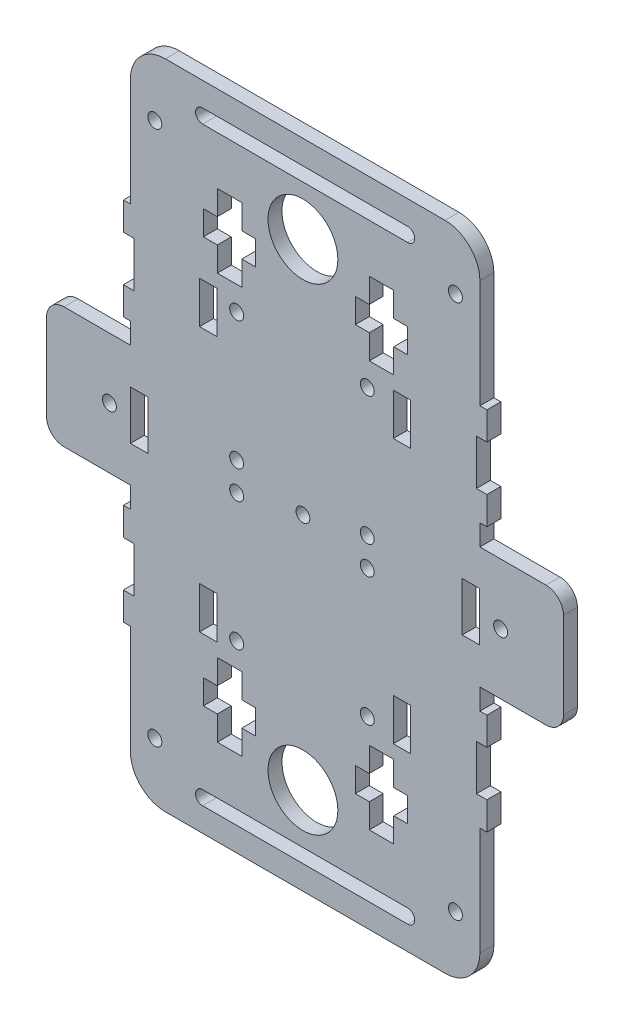
from build123d import *

# Parameters (mm, degrees)
SKETCH1_R           = 10
SKETCH1_R_2         = 1.972602619
BOSS_EXTRUDE2_DEPTH = 4
SKETCH5_W           = 5
SKETCH5_H           = 14
CUT_EXTRUDE3_DEPTH  = 5.0000001
SKETCH6_W           = 5
SKETCH6_H           = 14
CUT_EXTRUDE4_DEPTH  = 5.0000001
SKETCH19_R          = 2
CUT_EXTRUDE19_DEPTH = 5.0000001
SKETCH22_R          = 2
CUT_EXTRUDE22_DEPTH = 5.0000001
SKETCH23_R          = 2
CUT_EXTRUDE23_DEPTH = 5.0000001
SKETCH24_R          = 2
CUT_EXTRUDE24_DEPTH = 5.0000001
SKETCH25_W          = 5
SKETCH25_H          = 12
CUT_EXTRUDE25_DEPTH = 5.0000001
CUT_EXTRUDE26_DEPTH = 5.0000001
CUT_EXTRUDE29_DEPTH = 5.0000001
SKETCH20_R          = 2
CUT_EXTRUDE20_DEPTH = 5.0000001
SKETCH30_W          = 181.696441894
SKETCH30_H          = 131.456906608
CUT_EXTRUDE30_DEPTH = 4
SKETCH31_R          = 2
CUT_EXTRUDE31_DEPTH = 4
SKETCH32_W          = 167.461823271
SKETCH32_H          = 37.26795508
CUT_EXTRUDE32_DEPTH = 4
FILLET1_R           = 10
FILLET2_R           = 5
SKETCH33_W          = 2
SKETCH33_H          = 8
BOSS_EXTRUDE3_DEPTH = 4


with BuildPart() as part:
    # Sketch1 → Boss-Extrude2 (new body)
    with BuildSketch(Plane.XY):
        with BuildLine():
            Line((-49.4, 97.775402254), (-49.4, 48.775402254))
            Line((-49.4, 48.775402254), (-48.4, 48.775402254))
            Line((-48.4, 48.775402254), (-48.4, 35.775402254))
            Line((-48.4, 35.775402254), (-49.4, 35.775402254))
            Line((-49.4, 35.775402254), (-49.4, 21.775402254))
            Line((-49.4, 21.775402254), (-73.4, 21.775402254))
            Line((-73.4, 21.775402254), (-73.4, -12.924597746))
            Line((-73.4, -12.924597746), (-49.4, -12.924597746))
            Line((-49.4, -12.924597746), (-49.4, -26.924597746))
            Line((-49.4, -26.924597746), (-48.4, -26.924597746))
            Line((-48.4, -26.924597746), (-48.4, -39.924597746))
            Line((-48.4, -39.924597746), (-49.4, -39.924597746))
            Line((-49.4, -39.924597746), (-49.4, -88.924597746))
            Line((-49.4, -88.924597746), (-73.349457369, -88.924597746))
            add(Edge.make_bspline(
                [(-73.349457369, -88.924597746), (-70.502213021, -123.490651401), (3.447241601, -123.490651401), (77.396696223, -123.490651401), (74.549451875, -88.924597746)],
                knots=[3.190793702, 3.190793702, 3.190793702, 4.761590029, 4.761590029, 6.332386355, 6.332386355, 6.332386355], degree=2, weights=[1, 0.707106781, 1, 0.707106781, 1]))
            Line((74.549451875, -88.924597746), (50.599994505, -88.924597746))
            Line((50.599994505, -88.924597746), (50.599994505, -39.924597746))
            Line((50.599994505, -39.924597746), (49.599994505, -39.924597746))
            Line((49.599994505, -39.924597746), (49.599994505, -26.924597746))
            Line((49.599994505, -26.924597746), (50.599994505, -26.924597746))
            Line((50.599994505, -26.924597746), (50.599994505, -12.924597746))
            Line((50.599994505, -12.924597746), (74.599994505, -12.924597746))
            Line((74.599994505, -12.924597746), (74.599994505, 21.775402254))
            Line((74.599994505, 21.775402254), (50.669116659, 21.775402254))
            Line((50.669116659, 21.775402254), (50.669116659, 35.775402254))
            Line((50.669116659, 35.775402254), (49.669116659, 35.775402254))
            Line((49.669116659, 35.775402254), (49.669116659, 48.775402254))
            Line((49.669116659, 48.775402254), (50.669116659, 48.775402254))
            Line((50.669116659, 48.775402254), (50.669116659, 97.775402254))
            Line((50.669116659, 97.775402254), (74.669116659, 97.775402254))
            add(Edge.make_bspline(
                [(74.669116659, 97.775402254), (74.669116659, 132.775402254), (0.587265356, 132.775402254), (-73.494585946, 132.775402254), (-73.494585946, 97.775402254)],
                knots=[3.141592654, 3.141592654, 3.141592654, 4.71238898, 4.71238898, 6.283185307, 6.283185307, 6.283185307], degree=2, weights=[1, 0.707106781, 1, 0.707106781, 1]))
            Line((-73.494585946, 97.775402254), (-49.4, 97.775402254))
        make_face()
        with Locations((0, 72.732378713)):
            Circle(SKETCH1_R, mode=Mode.SUBTRACT)
        with Locations((0, -63.883577786)):
            Circle(SKETCH1_R, mode=Mode.SUBTRACT)
        with Locations((0, 4.424400463)):
            Circle(SKETCH1_R_2, mode=Mode.SUBTRACT)
    extrude(amount=BOSS_EXTRUDE2_DEPTH)

    # Sketch5 → Cut-Extrude3 (cut, through all)
    with BuildSketch(Plane(origin=(0, 0, 0), x_dir=(-1, 0, 0), z_dir=(0, 0, -1))):
        with Locations((46.9, 4.425402254)):
            Rectangle(SKETCH5_W, SKETCH5_H)
    extrude(amount=-CUT_EXTRUDE3_DEPTH, mode=Mode.SUBTRACT)

    # Sketch6 → Cut-Extrude4 (cut, through all)
    with BuildSketch(Plane(origin=(0, 0, 0), x_dir=(-1, 0, 0), z_dir=(0, 0, -1))):
        with Locations((-48.099994505, 4.425402254)):
            Rectangle(SKETCH6_W, SKETCH6_H)
    extrude(amount=-CUT_EXTRUDE4_DEPTH, mode=Mode.SUBTRACT)

    # Sketch19 → Cut-Extrude19 (cut, through all)
    with BuildSketch(Plane(origin=(0, 0, 0), x_dir=(-1, 0, 0), z_dir=(0, 0, -1))):
        with Locations((-56.599994505, 4.425402254)):
            Circle(SKETCH19_R)
    extrude(amount=-CUT_EXTRUDE19_DEPTH, mode=Mode.SUBTRACT)

    # Sketch22 → Cut-Extrude22 (cut, through all)
    with BuildSketch(Plane(origin=(0, 0, 0), x_dir=(-1, 0, 0), z_dir=(0, 0, -1))):
        with Locations((42.4, 81)):
            Circle(SKETCH22_R)
        with Locations((-43.669116659, 81)):
            Circle(SKETCH22_R)
    extrude(amount=-CUT_EXTRUDE22_DEPTH, mode=Mode.SUBTRACT)

    # Sketch23 → Cut-Extrude23 (cut, through all)
    with BuildSketch(Plane.XY.offset(4)):
        with Locations((43.599994505, -81)):
            Circle(SKETCH23_R)
        with Locations((-42.4, -81)):
            Circle(SKETCH23_R)
    extrude(amount=-CUT_EXTRUDE23_DEPTH, mode=Mode.SUBTRACT)

    # Sketch24 → Cut-Extrude24 (cut, through all)
    with BuildSketch(Plane.XY.offset(4)):
        with Locations((-50, -94.924597746)):
            Circle(SKETCH24_R)
        with Locations((50, -94.924597746)):
            Circle(SKETCH24_R)
        with Locations((-50, 103.775402254)):
            Circle(SKETCH24_R)
        with Locations((50, 103.775402254)):
            Circle(SKETCH24_R)
    extrude(amount=-CUT_EXTRUDE24_DEPTH, mode=Mode.SUBTRACT)

    # Sketch25 → Cut-Extrude25 (cut, through all)
    with BuildSketch(Plane(origin=(0, 0, 0), x_dir=(-1, 0, 0), z_dir=(0, 0, -1))):
        with Locations((-28.369116659, 42.275402254)):
            Rectangle(SKETCH25_W, SKETCH25_H)
        with Locations((27.1, 42.275402254)):
            Rectangle(SKETCH25_W, SKETCH25_H)
        with Locations((-28.299994505, -33.424597746)):
            Rectangle(SKETCH25_W, SKETCH25_H)
        with Locations((27.1, -33.424597746)):
            Rectangle(SKETCH25_W, SKETCH25_H)
    extrude(amount=-CUT_EXTRUDE25_DEPTH, mode=Mode.SUBTRACT)

    # Sketch26 → Cut-Extrude26 (cut, through all)
    with BuildSketch(Plane(origin=(0, 0, 0), x_dir=(-1, 0, 0), z_dir=(0, 0, -1))):
        Polygon((24.510151311, 52.075402254), (17.510151311, 52.075402254), (17.510151311, 59.075402254), (13.510151311, 59.075402254), (13.510151311, 66.075402254), (17.510151311, 66.075402254), (17.510151311, 73.075402254), (24.510151311, 73.075402254), (24.510151311, 66.075402254), (28.510151311, 66.075402254), (28.510151311, 59.075402254), (24.510151311, 59.075402254), align=None)
        Polygon((-29.999116659, 59.075402254), (-29.999116659, 66.075402254), (-25.999116659, 66.075402254), (-25.999116659, 73.075402254), (-18.999116659, 73.075402254), (-18.999116659, 66.075402254), (-14.999116659, 66.075402254), (-14.999116659, 59.075402254), (-18.999116659, 59.075402254), (-18.999116659, 52.075402254), (-25.999116659, 52.075402254), (-25.999116659, 59.075402254), align=None)
        Polygon((-19, -69), (-19, -62), (-15, -62), (-15, -55), (-19, -55), (-19, -48), (-26, -48), (-26, -55), (-30, -55), (-30, -62), (-26, -62), (-26, -69), align=None)
        Polygon((24.510151311, -48), (17.510151311, -48), (17.510151311, -55), (13.510151311, -55), (13.510151311, -62), (17.510151311, -62), (17.510151311, -69), (24.510151311, -69), (24.510151311, -62), (28.510151311, -62), (28.510151311, -55), (24.510151311, -55), align=None)
    extrude(amount=-CUT_EXTRUDE26_DEPTH, mode=Mode.SUBTRACT)

    # Sketch28 → Cut-Extrude29 (cut, through all)
    with BuildSketch(Plane(origin=(0, 0, 0), x_dir=(-1, 0, 0), z_dir=(0, 0, -1))):
        with BuildLine():
            Line((28.730883341, 86.928533544), (-30, 86.928533544))
            ThreePointArc((-30, 86.928533544), (-32, 88.928533544), (-30, 90.928533544))
            Line((-30, 90.928533544), (28.730883341, 90.928533544))
            ThreePointArc((28.730883341, 90.928533544), (30.730883341, 88.928533544), (28.730883341, 86.928533544))
        make_face()
    extrude(amount=-CUT_EXTRUDE29_DEPTH, mode=Mode.SUBTRACT)

    # Sketch20 → Cut-Extrude20 (cut, through all)
    with BuildSketch(Plane(origin=(0, 0, 0), x_dir=(-1, 0, 0), z_dir=(0, 0, -1))):
        with Locations((55.4, 4.425402254)):
            Circle(SKETCH20_R)
    extrude(amount=-CUT_EXTRUDE20_DEPTH, mode=Mode.SUBTRACT)

    # Sketch30 → Cut-Extrude30 (cut)
    with BuildSketch(Plane(origin=(0, 0, 0), x_dir=(-1, 0, 0), z_dir=(0, 0, -1))):
        with Locations((-2.534318945, -61.30305105)):
            Rectangle(SKETCH30_W, SKETCH30_H)
    extrude(amount=-CUT_EXTRUDE30_DEPTH, mode=Mode.SUBTRACT)

    # Sketch31 → Cut-Extrude31 (cut)
    with BuildSketch(Plane(origin=(0, 0, 0), x_dir=(-1, 0, 0), z_dir=(0, 0, -1))):
        with Locations((-18.412976441, 45.21289193)):
            Circle(SKETCH31_R)
        with Locations((-18.413659383, 8.47289193)):
            Circle(SKETCH31_R)
        with Locations((18.967023559, 45.21289193)):
            Circle(SKETCH31_R)
        with Locations((18.966340617, 8.47289193)):
            Circle(SKETCH31_R)
    extrude(amount=-CUT_EXTRUDE31_DEPTH, mode=Mode.SUBTRACT)

    # Sketch32 → Cut-Extrude32 (cut)
    with BuildSketch(Plane(origin=(0, 0, 0), x_dir=(-1, 0, 0), z_dir=(0, 0, -1))):
        with Locations((-4.661465148, 116.409379794)):
            Rectangle(SKETCH32_W, SKETCH32_H)
    extrude(amount=-CUT_EXTRUDE32_DEPTH, mode=Mode.SUBTRACT)

    # Fillet1
    fillet1_edges = [part.edges().sort_by_distance(p)[0] for p in [
        (-49.4, 97.775402254, 2),
        (50.669116659, 97.775402254, 2),
    ]]
    fillet(fillet1_edges, radius=FILLET1_R)

    # Fillet2
    fillet2_edges = [part.edges().sort_by_distance(p)[0] for p in [
        (74.599994505, 21.775402254, 2),
        (-73.4, 21.775402254, 2),
    ]]
    fillet(fillet2_edges, radius=FILLET2_R)

    # Sketch33 → Boss-Extrude3 (add)
    with BuildSketch(Plane.XY.offset(4)):
        with Locations((51.669116659, 52.775402254)):
            Rectangle(SKETCH33_W, SKETCH33_H)
        with Locations((51.669116659, 31.775402254)):
            Rectangle(SKETCH33_W, SKETCH33_H)
        with Locations((-50.4, 31.775402254)):
            Rectangle(SKETCH33_W, SKETCH33_H)
        with Locations((-50.4, 52.775402254)):
            Rectangle(SKETCH33_W, SKETCH33_H)
    extrude(amount=-BOSS_EXTRUDE3_DEPTH)

    # Mirror1: part across plane


with BuildPart() as part_1:
    add(part.part)
    add(part.part.mirror(Plane(origin=(0, 4.425402254, 0), x_dir=(0, 0, 1), z_dir=(0, -1, 0))))


solid = part_1.part
